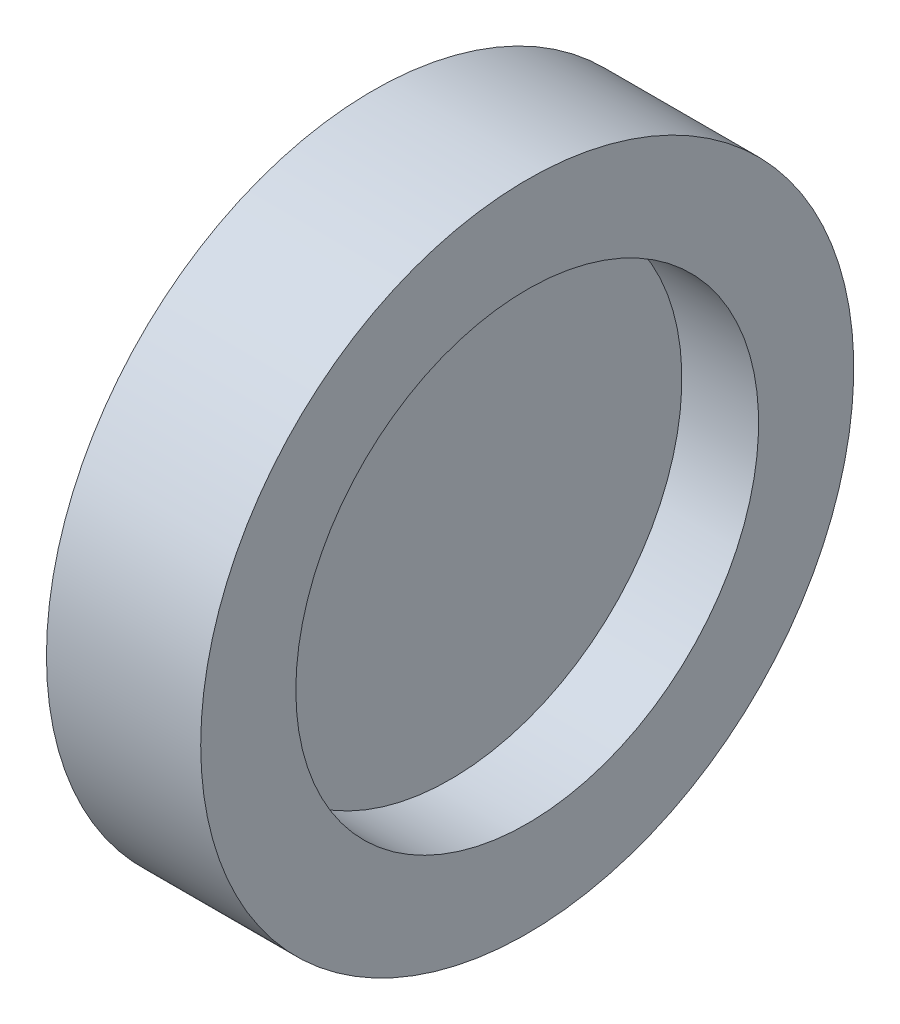
from build123d import *

# Parameters (mm, degrees)
SKETCH_1_W = 0.027
SKETCH_1_H = 9
SKETCH_4_W = 6
SKETCH_4_H = 3.7


with BuildPart() as part:
    # 草图1 → 旋转2 (revolve)
    with BuildSketch(Plane.XY, mode=Mode.PRIVATE) as revolve_2_sk:
        with Locations((0, 4.5)):
            Rectangle(SKETCH_1_W, SKETCH_1_H)
    revolve(revolve_2_sk.sketch.rotate(Axis((-0.0135, 0, 0), (1, 0, 0)), 90), axis=Axis((-0.0135, 0, 0), (1, 0, 0)))  # turned: the seam where the file's is

    # 草图4 → 旋转3 (revolve)
    with BuildSketch(Plane.XY, mode=Mode.PRIVATE) as revolve_3_sk:
        with Locations((0, 10.85)):
            Rectangle(SKETCH_4_W, SKETCH_4_H)
    revolve(revolve_3_sk.sketch.rotate(Axis((-1.614212419, 0, 0), (1, 0, 0)), 90), axis=Axis((-1.614212419, 0, 0), (1, 0, 0)))  # turned: the seam where the file's is


solid = part.part
